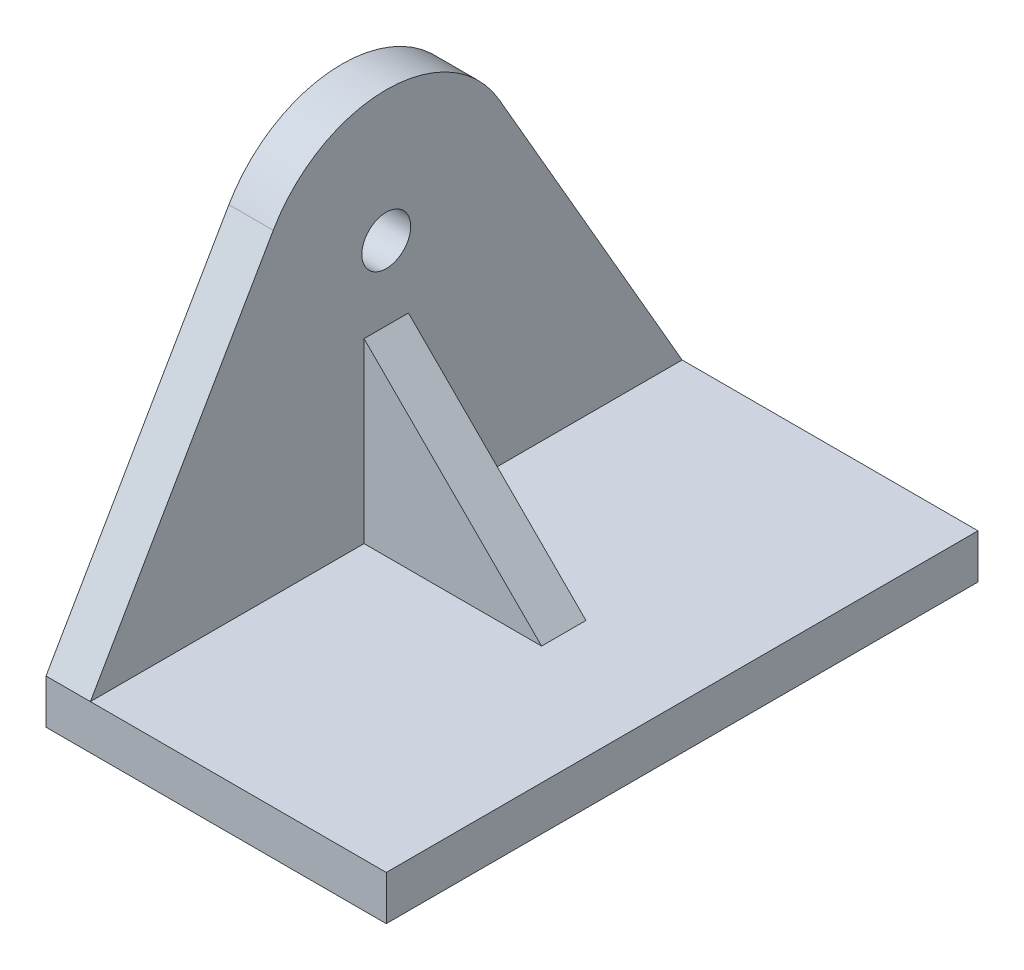
from build123d import *

# Parameters (mm, degrees)
EXTRUDE_1_DEPTH     = 3
SKETCH_2_R          = 1.65
CUT_EXTRUDE_1_DEPTH = 4
SKETCH_3_W          = 40
SKETCH_3_H          = 3
EXTRUDE_2_DEPTH     = 20
EXTRUDE_3_DEPTH     = 1.5


with BuildPart() as part:
    # 草图1 → 凸台-拉伸1 (new body)
    with BuildSketch(Plane(origin=(0, 0, 0), x_dir=(0, 0, -1), z_dir=(1, 0, 0))):
        with BuildLine():
            Line((-20, 0), (20, 0))
            Line((20, 0), (20, 3))
            Line((20, 3), (7.638784068, 24.410254038))
            ThreePointArc((7.638784068, 24.410254038), (0, 28.820508076), (-7.638784068, 24.410254038))
            Line((-7.638784068, 24.410254038), (-20, 3))
            Line((-20, 3), (-20, 0))
        make_face()
    extrude(amount=-EXTRUDE_1_DEPTH)

    # 草图2 → 切除-拉伸1 (cut, through all)
    with BuildSketch(Plane(origin=(0, 0, 0), x_dir=(0, 0, -1), z_dir=(1, 0, 0))):
        with Locations((0, 20)):
            Circle(SKETCH_2_R)
    extrude(amount=-CUT_EXTRUDE_1_DEPTH, mode=Mode.SUBTRACT)

    # 草图3 → 凸台-拉伸2 (add)
    with BuildSketch(Plane(origin=(0, 0, 0), x_dir=(0, 0, -1), z_dir=(1, 0, 0))):
        with Locations((0, 1.5)):
            Rectangle(SKETCH_3_W, SKETCH_3_H)
    extrude(amount=EXTRUDE_2_DEPTH)

    # 草图4 → 凸台-拉伸3 (add, symmetric)
    with BuildSketch(Plane.XY):
        Polygon((0, 3), (0, 15), (12, 3), align=None)
    extrude(amount=EXTRUDE_3_DEPTH, both=True)


solid = part.part
